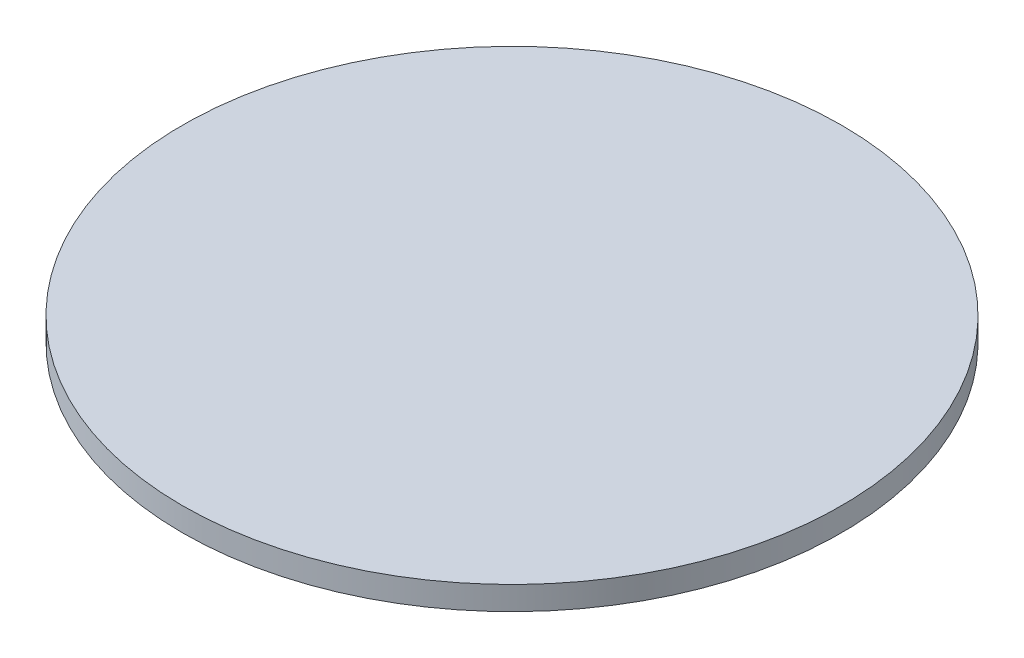
from build123d import *

# Parameters (mm, degrees)
SKETCH1_R           = 177.8
BOSS_EXTRUDE1_DEPTH = 6.35


with BuildPart() as part:
    # Sketch1 → Boss-Extrude1 (new body, symmetric)
    with BuildSketch(Plane(origin=(0, 0, 0), x_dir=(1, 0, 0), z_dir=(0, 1, 0))):
        Circle(SKETCH1_R)
    extrude(amount=BOSS_EXTRUDE1_DEPTH, both=True)


solid = part.part
